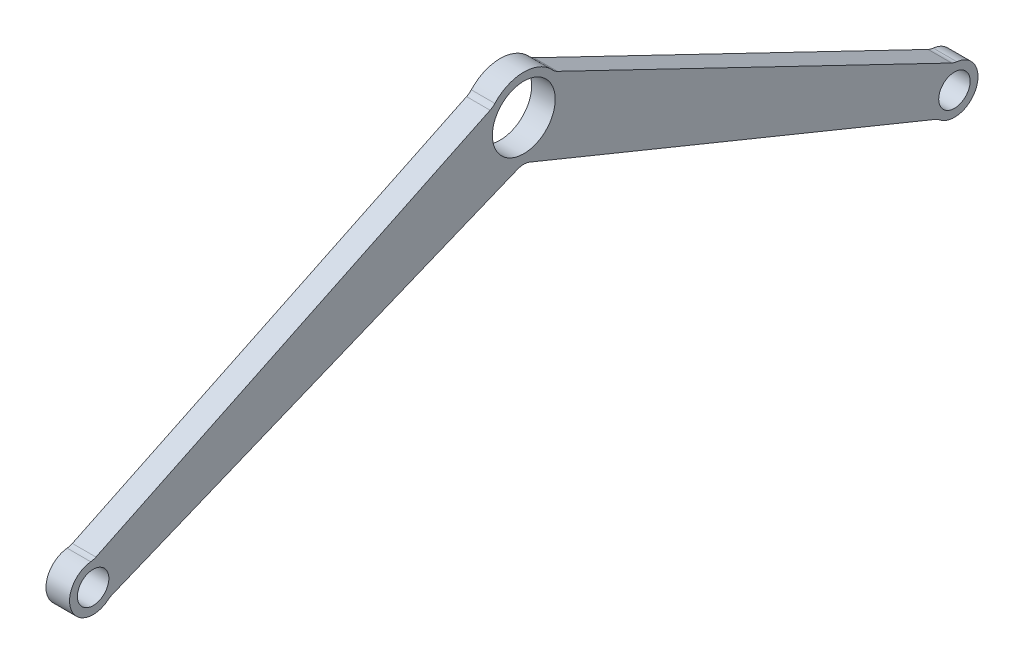
from build123d import *

# Parameters (mm, degrees)
SKETCH1_R           = 40
SKETCH1_R_2         = 20
BOSS_EXTRUDE1_DEPTH = 30
FILLET1_R           = 20


with BuildPart() as part:
    # Sketch1 → Boss-Extrude1 (new body)
    with BuildSketch(Plane(origin=(0, 0, 0), x_dir=(0, 0, -1), z_dir=(1, 0, 0))):
        with BuildLine():
            Line((548.127274586, -214.041985845), (39.098756603, 31.16548142))
            ThreePointArc((39.098756603, 31.16548142), (0, 50), (-39.098756603, 31.16548142))
            Line((-39.098756603, 31.16548142), (-548.127274586, -214.041985845))
            ThreePointArc((-548.127274586, -214.041985845), (-575.897089096, -255.392642304), (-527.11356629, -265.452825709))
            Line((-527.11356629, -265.452825709), (0, -50))
            Line((0, -50), (527.11356629, -265.452825709))
            ThreePointArc((527.11356629, -265.452825709), (575.897089096, -255.392642304), (548.127274586, -214.041985845))
        make_face()
        Circle(SKETCH1_R, mode=Mode.SUBTRACT)
        with Locations((-548.127274586, -244.041985845)):
            Circle(SKETCH1_R_2, mode=Mode.SUBTRACT)
        with Locations((548.127274586, -244.041985845)):
            Circle(SKETCH1_R_2, mode=Mode.SUBTRACT)
    extrude(amount=BOSS_EXTRUDE1_DEPTH)

    # Fillet1
    fillet1_edges = [part.edges().sort_by_distance(p)[0] for p in [
        (15, -265.452825709, -527.11356629),
        (15, -214.041985845, -548.127274586),
        (15, 31.16548142, -39.098756603),
        (15, -214.041985845, 548.127274586),
        (15, 31.16548142, 39.098756603),
        (15, -50, 0),
        (15, -265.452825709, 527.11356629),
    ]]
    fillet(fillet1_edges, radius=FILLET1_R)


solid = part.part
